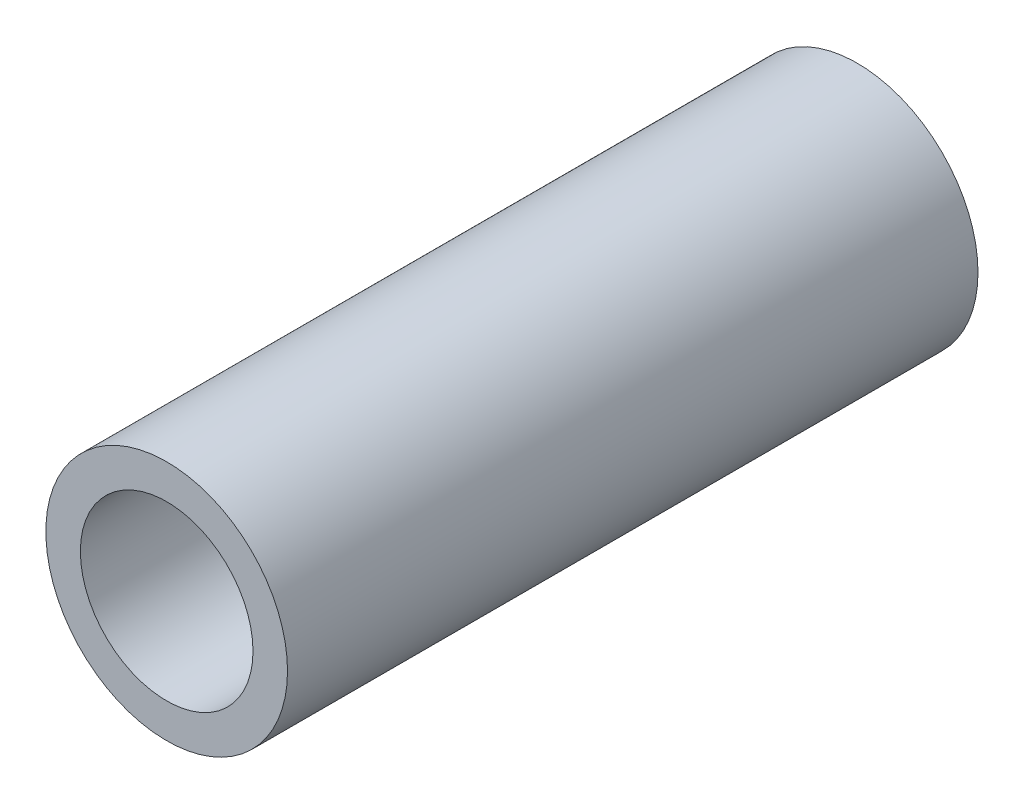
from build123d import *

# Parameters (mm, degrees)
SKETCH1_R           = 8.89
SKETCH1_R_2         = 6.35
EXTRUDE_THIN1_DEPTH = 50.8
SKETCH2_R           = 6.35
BOSS_EXTRUDE1_DEPTH = 2.54


with BuildPart() as part:
    # Sketch1 → Extrude-Thin1 (new body)
    with BuildSketch(Plane.XY):
        Circle(SKETCH1_R)
        Circle(SKETCH1_R_2, mode=Mode.SUBTRACT)
    extrude(amount=EXTRUDE_THIN1_DEPTH)

    # Sketch2 → Boss-Extrude1 (add)
    with BuildSketch(Plane(origin=(0, 0, 0), x_dir=(-1, 0, 0), z_dir=(0, 0, -1))):
        Circle(SKETCH2_R)
    extrude(amount=-BOSS_EXTRUDE1_DEPTH)


solid = part.part
